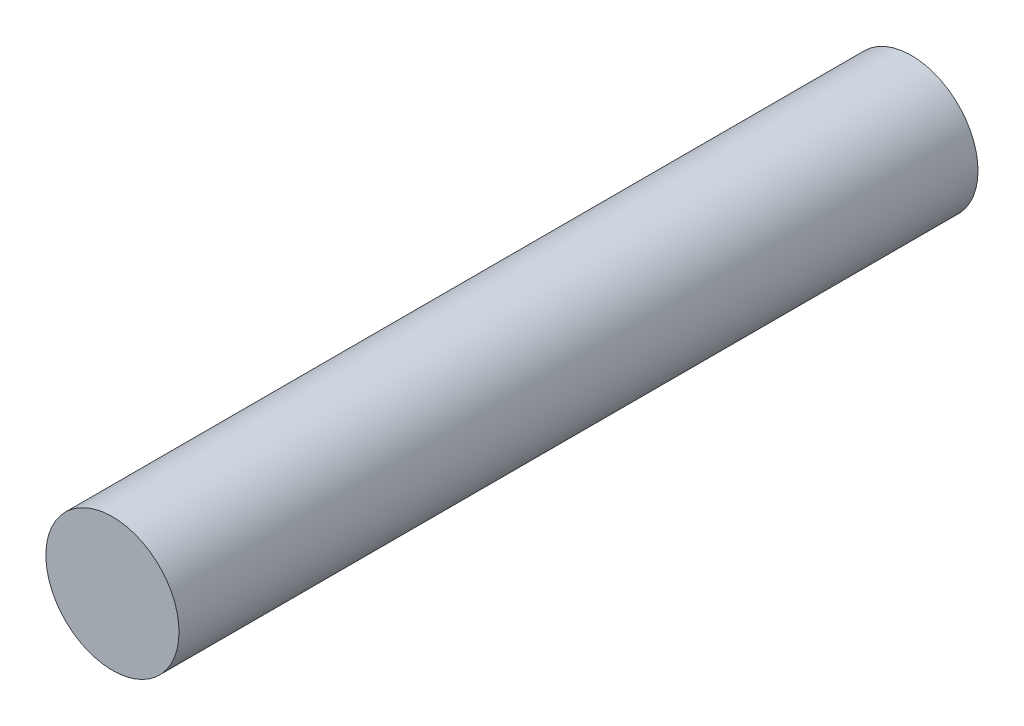
from build123d import *

# Parameters (mm, degrees)
IZIM1_R                     = 2.5
Y_KSEKLIK_EKSTR_ZYON1_DEPTH = 15


with BuildPart() as part:
    # Çizim1 → Yükseklik-Ekstrüzyon1 (new body, symmetric)
    with BuildSketch(Plane.XY):
        Circle(IZIM1_R)
    extrude(amount=Y_KSEKLIK_EKSTR_ZYON1_DEPTH, both=True)


solid = part.part
